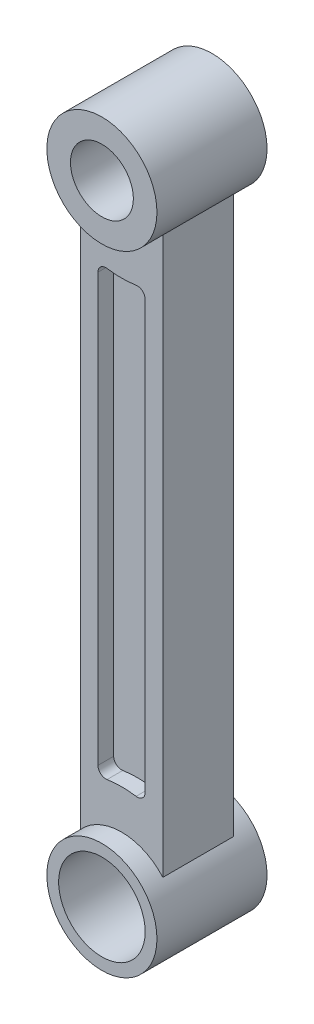
from build123d import *

# Parameters (mm, degrees)
SKETCH1_R           = 7
SKETCH1_R_2         = 5.5
BOSS_EXTRUDE1_DEPTH = 7
SKETCH2_R           = 7
SKETCH2_R_2         = 4
BOSS_EXTRUDE2_DEPTH = 7
BOSS_EXTRUDE3_DEPTH = 4.5
CUT_EXTRUDE2_DEPTH  = 2


with BuildPart() as part:
    # Sketch1 → Boss-Extrude1 (new body, symmetric)
    with BuildSketch(Plane.XY):
        Circle(SKETCH1_R)
        Circle(SKETCH1_R_2, mode=Mode.SUBTRACT)
    extrude(amount=BOSS_EXTRUDE1_DEPTH, both=True)



with BuildPart() as body_2:
    # Sketch2 → Boss-Extrude2 (new body, symmetric)
    with BuildSketch(Plane.XY):
        with Locations((0, 80)):
            Circle(SKETCH2_R)
        with Locations((0, 80)):
            Circle(SKETCH2_R_2, mode=Mode.SUBTRACT)
    extrude(amount=BOSS_EXTRUDE2_DEPTH, both=True)


with BuildPart() as part_1:
    add(part.part)

    add(body_2.part)  # Boss-Extrude3 merges body 2
    # Sketch3 → Boss-Extrude3 (add, symmetric)
    with BuildSketch(Plane.XY):
        with BuildLine():
            Line((-5.25, 75.369935206), (-5.25, 4.630064794))
            ThreePointArc((-5.25, 4.630064794), (0, 7), (5.25, 4.630064794))
            Line((5.25, 4.630064794), (5.25, 75.369935206))
            ThreePointArc((5.25, 75.369935206), (0, 73), (-5.25, 75.369935206))
        make_face()
    extrude(amount=BOSS_EXTRUDE3_DEPTH, both=True)

    # Sketch4 → Cut-Extrude2 (cut)
    with BuildSketch(Plane.XY.offset(4.5)):
        with BuildLine():
            ThreePointArc((-3, 67.154767421), (-2.650443636, 67.914321947), (-1.846153846, 68.142862235))
            ThreePointArc((-1.846153846, 68.142862235), (0, 68), (1.846153846, 68.142862235))
            ThreePointArc((1.846153846, 68.142862235), (2.650443636, 67.914321947), (3, 67.154767421))
            Line((3, 67.154767421), (3, 12.845232579))
            ThreePointArc((3, 12.845232579), (2.650443636, 12.085678053), (1.846153846, 11.857137765))
            ThreePointArc((1.846153846, 11.857137765), (0, 12), (-1.846153846, 11.857137765))
            ThreePointArc((-1.846153846, 11.857137765), (-2.650443636, 12.085678053), (-3, 12.845232579))
            Line((-3, 12.845232579), (-3, 67.154767421))
        make_face()
    cut_extrude2 = extrude(amount=-CUT_EXTRUDE2_DEPTH, mode=Mode.SUBTRACT)

    # Mirror1: Cut-Extrude2 across plane
    add(cut_extrude2.mirror(Plane.XY), mode=Mode.SUBTRACT)


solid = part_1.part
